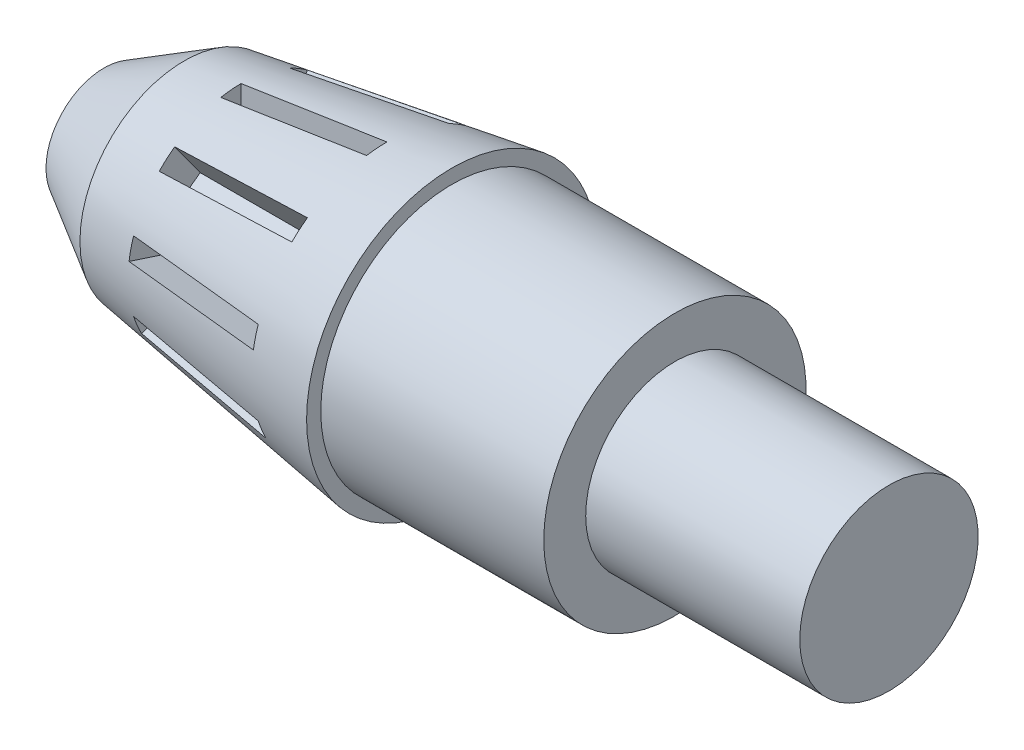
from build123d import *

# Parameters (mm, degrees)
SKETCH2_W           = 16.351115912
SKETCH2_H           = 2.286251171
CUT_EXTRUDE2_DEPTH  = 8
CIRPATTERN1_COUNT   = 10
BOSS_EXTRUDE2_DEPTH = 23
CIRPATTERN2_COUNT   = 3


with BuildPart() as part:
    # Sketch1 → Revolve1 (revolve)
    with BuildSketch(Plane.XY):
        Polygon((-45, 22.5), (-20, 22.5), (-20, 17.8), (4, 17.8), (4, 7.8), (-59, 7.8), (-59, 13), (-84, 13), (-84, 14.303183025), (-75, 19.499335448), (-45, 24.089980537), align=None)
    revolve(axis=Axis((-59, 7.8, 0), (1, 0, 0)))

    # Sketch2 → Cut-Extrude2 (cut)
    with BuildSketch(Plane(origin=(0, 0, 0), x_dir=(1, 0, 0), z_dir=(0, 1, 0))):
        with Locations((-60.455240296, 1.143125585)):
            Rectangle(SKETCH2_W, SKETCH2_H)
    cut_extrude2 = extrude(amount=-CUT_EXTRUDE2_DEPTH, mode=Mode.SUBTRACT)

    # CirPattern1: Cut-Extrude2 ×10 about axis
    cirpattern1_axis = Axis((0, 7.8, 0), (1, 0, 0))
    for i in range(1, CIRPATTERN1_COUNT):
        add(cut_extrude2.rotate(cirpattern1_axis, i * 360 / CIRPATTERN1_COUNT), mode=Mode.SUBTRACT)

    # Sketch3 → Boss-Extrude2 (add)
    with BuildSketch(Plane.ZY.offset(59)):
        with BuildLine():
            ThreePointArc((2.388609227, 12.418933423), (0.326387029, 12.989746767), (-1.791101139, 12.681798512))
            Line((-1.791101139, 12.681798512), (-0.861106317, 10.147018515))
            ThreePointArc((-0.861106317, 10.147018515), (0.156916841, 10.295070561), (1.148369821, 10.020641069))
            Line((1.148369821, 10.020641069), (2.388609227, 12.418933423))
        make_face()
    boss_extrude2 = extrude(amount=BOSS_EXTRUDE2_DEPTH)

    # CirPattern2: Boss-Extrude2 ×3 about axis
    cirpattern2_axis = Axis((0, 7.8, 0), (1, 0, 0))
    for i in range(1, CIRPATTERN2_COUNT):
        add(boss_extrude2.rotate(cirpattern2_axis, i * 360 / CIRPATTERN2_COUNT))


solid = part.part
